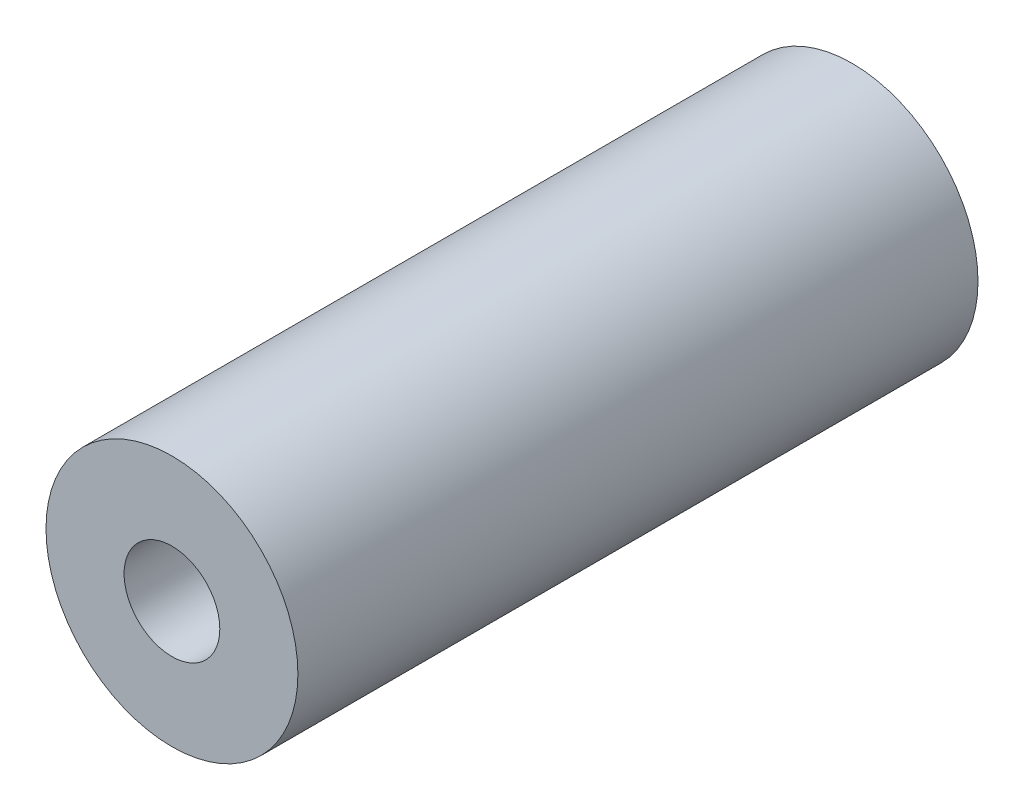
from build123d import *

# Parameters (mm, degrees)
SKETCH2_R           = 6.35
SKETCH2_R_2         = 2.413
BOSS_EXTRUDE1_DEPTH = 34.29


with BuildPart() as part:
    # Sketch2 → Boss-Extrude1 (new body)
    with BuildSketch(Plane.XY):
        Circle(SKETCH2_R)
        Circle(SKETCH2_R_2, mode=Mode.SUBTRACT)
    extrude(amount=BOSS_EXTRUDE1_DEPTH)


solid = part.part
